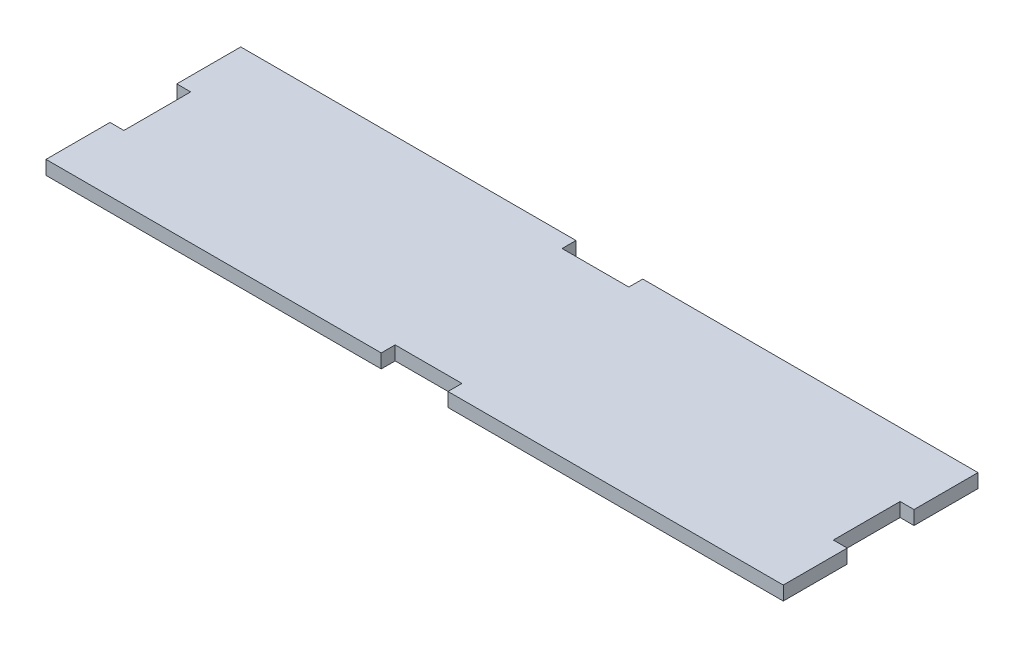
from build123d import *

# Parameters (mm, degrees)
SKETCH1_W           = 336.55
SKETCH1_H           = 88.9
BOSS_EXTRUDE1_DEPTH = 6.35
SKETCH2_W           = 30.48
SKETCH2_H           = 6.35
SKETCH2_W_2         = 6.35
SKETCH2_H_2         = 30.48
CUT_EXTRUDE1_DEPTH  = 7.35


with BuildPart() as part:
    # Sketch1 → Boss-Extrude1 (new body)
    with BuildSketch(Plane(origin=(0, 0, 0), x_dir=(1, 0, 0), z_dir=(0, 1, 0))):
        with Locations((-168.275, -44.45)):
            Rectangle(SKETCH1_W, SKETCH1_H)
    extrude(amount=BOSS_EXTRUDE1_DEPTH)

    # Sketch2 → Cut-Extrude1 (cut, through all)
    with BuildSketch(Plane(origin=(0, 6.35, 0), x_dir=(1, 0, 0), z_dir=(0, 1, 0))):
        with Locations((-168.275, -3.175)):
            Rectangle(SKETCH2_W, SKETCH2_H)
        with Locations((-168.275, -85.725)):
            Rectangle(SKETCH2_W, SKETCH2_H)
        with Locations((-3.175, -44.45)):
            Rectangle(SKETCH2_W_2, SKETCH2_H_2)
        with Locations((-333.375, -44.45)):
            Rectangle(SKETCH2_W_2, SKETCH2_H_2)
    extrude(amount=-CUT_EXTRUDE1_DEPTH, mode=Mode.SUBTRACT)


solid = part.part
